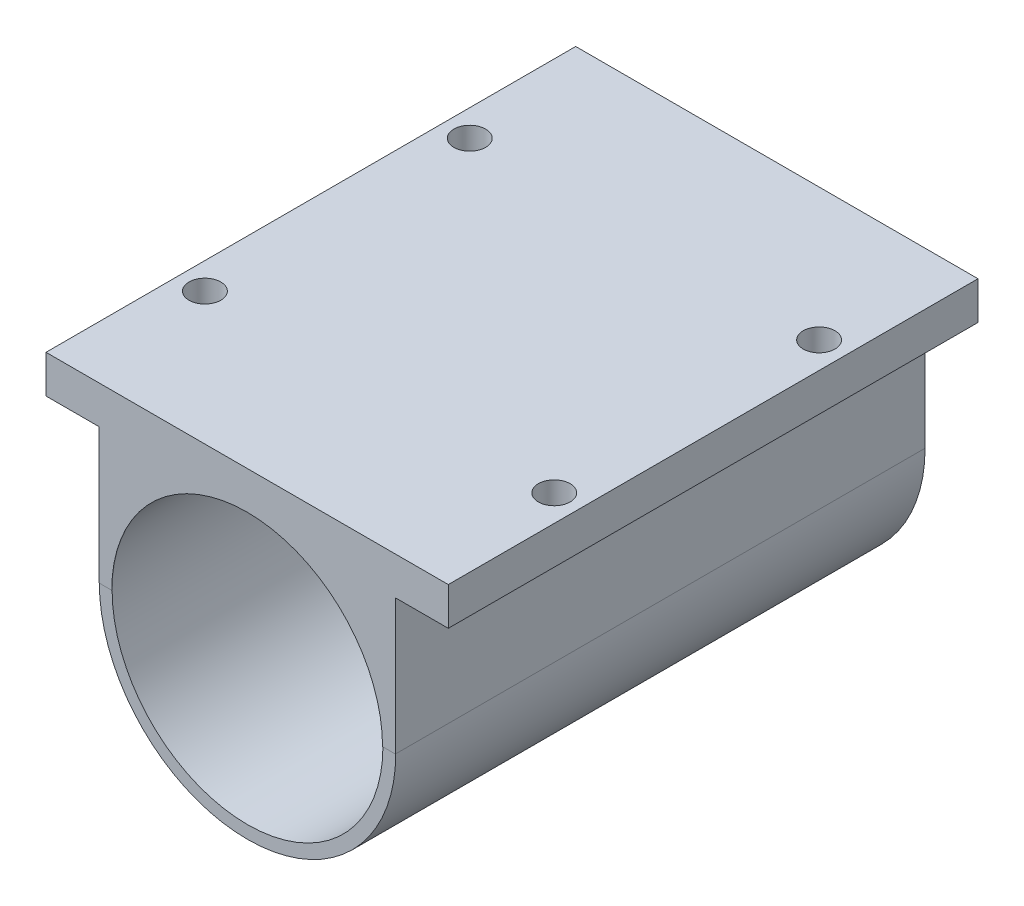
from build123d import *

# Parameters (mm, degrees)
SKETCH1_R           = 14
BOSS_EXTRUDE1_DEPTH = 50
SKETCH5_W           = 28
SKETCH5_H           = 50.034880911
BOSS_EXTRUDE2_DEPTH = 21
SKETCH2_R           = 12.791811967
CUT_EXTRUDE1_DEPTH  = 48
SKETCH3_R           = 4
CUT_EXTRUDE2_DEPTH  = 49
SKETCH4_R           = 1.5
CUT_EXTRUDE3_DEPTH  = 49
SKETCH6_R           = 12.79
CUT_EXTRUDE5_DEPTH  = 21
SKETCH7_W           = 28
SKETCH7_H           = 4.634699127
CUT_EXTRUDE6_DEPTH  = 53
SKETCH8_W           = 50.034880911
SKETCH8_H           = 3.58
BOSS_EXTRUDE3_DEPTH = 5
SKETCH13_R          = 1.5
CUT_EXTRUDE7_DEPTH  = 5
SKETCH14_W          = 50.034880911
SKETCH14_H          = 3.58
BOSS_EXTRUDE4_DEPTH = 5
SKETCH15_R          = 1.5
CUT_EXTRUDE8_DEPTH  = 5
FILLET1_R           = 1
FILLET2_R           = 1


with BuildPart() as part:
    # Sketch1 → Boss-Extrude1 (new body)
    with BuildSketch(Plane.XY):
        Circle(SKETCH1_R)
    extrude(amount=BOSS_EXTRUDE1_DEPTH)

    # Sketch5 → Boss-Extrude2 (add)
    with BuildSketch(Plane(origin=(0, 0, 0), x_dir=(1, 0, 0), z_dir=(0, 1, 0))):
        with Locations((0, -25.017440456)):
            Rectangle(SKETCH5_W, SKETCH5_H)
    extrude(amount=BOSS_EXTRUDE2_DEPTH)

    # Sketch2 → Cut-Extrude1 (cut)
    with BuildSketch(Plane.XY.offset(50)):
        Circle(SKETCH2_R)
    extrude(amount=-CUT_EXTRUDE1_DEPTH, mode=Mode.SUBTRACT)

    # Sketch3 → Cut-Extrude2 (cut)
    with BuildSketch(Plane(origin=(0, 0, 0), x_dir=(-1, 0, 0), z_dir=(0, 0, -1))):
        Circle(SKETCH3_R)
    extrude(amount=-CUT_EXTRUDE2_DEPTH, mode=Mode.SUBTRACT)

    # Sketch4 → Cut-Extrude3 (cut)
    with BuildSketch(Plane(origin=(0, 0, 0), x_dir=(-1, 0, 0), z_dir=(0, 0, -1))):
        with Locations((0, -8.5)):
            Circle(SKETCH4_R)
        with Locations((0, 8.5)):
            Circle(SKETCH4_R)
        with Locations((8.5, 0)):
            Circle(SKETCH4_R)
        with Locations((-8.5, 0)):
            Circle(SKETCH4_R)
    extrude(amount=-CUT_EXTRUDE3_DEPTH, mode=Mode.SUBTRACT)

    # Sketch6 → Cut-Extrude5 (cut)
    with BuildSketch(Plane.XY.offset(50.034880911)):
        Circle(SKETCH6_R)
    extrude(amount=-CUT_EXTRUDE5_DEPTH, mode=Mode.SUBTRACT)

    # Sketch7 → Cut-Extrude6 (cut)
    with BuildSketch(Plane.XY.offset(50.034880911)):
        with Locations((0, 18.682650437)):
            Rectangle(SKETCH7_W, SKETCH7_H)
    extrude(amount=-CUT_EXTRUDE6_DEPTH, mode=Mode.SUBTRACT)

    # Sketch8 → Boss-Extrude3 (add)
    with BuildSketch(Plane(origin=(14, 0, 0), x_dir=(0, 0, -1), z_dir=(1, 0, 0))):
        with Locations((-25.017440456, 14.575300873)):
            Rectangle(SKETCH8_W, SKETCH8_H)
    extrude(amount=BOSS_EXTRUDE3_DEPTH)

    # Sketch13 → Cut-Extrude7 (cut)
    with BuildSketch(Plane.XZ.offset(-12.785300873)):
        with Locations((16.5, 37.526160683)):
            Circle(SKETCH13_R)
        with Locations((16.5, 12.508720228)):
            Circle(SKETCH13_R)
    extrude(amount=-CUT_EXTRUDE7_DEPTH, mode=Mode.SUBTRACT)

    # Sketch14 → Boss-Extrude4 (add)
    with BuildSketch(Plane.ZY.offset(14)):
        with Locations((25.017440456, 14.575300873)):
            Rectangle(SKETCH14_W, SKETCH14_H)
    extrude(amount=BOSS_EXTRUDE4_DEPTH)

    # Sketch15 → Cut-Extrude8 (cut)
    with BuildSketch(Plane.XZ.offset(-12.785300873)):
        with Locations((-16.5, 12.508720228)):
            Circle(SKETCH15_R)
        with Locations((-16.5, 37.526160683)):
            Circle(SKETCH15_R)
    extrude(amount=-CUT_EXTRUDE8_DEPTH, mode=Mode.SUBTRACT)

    # Fillet1
    fillet1_edges = [part.edges().sort_by_distance(p)[0] for p in [
        (10, 0, 0),
    ]]
    fillet(fillet1_edges, radius=FILLET1_R)

    # Fillet2
    fillet2_edges = [part.edges().sort_by_distance(p)[0] for p in [
        (1.5, -8.5, 0),
        (1.5, 8.5, 0),
        (-7, 0, 0),
    ]]
    fillet(fillet2_edges, radius=FILLET2_R)


solid = part.part
